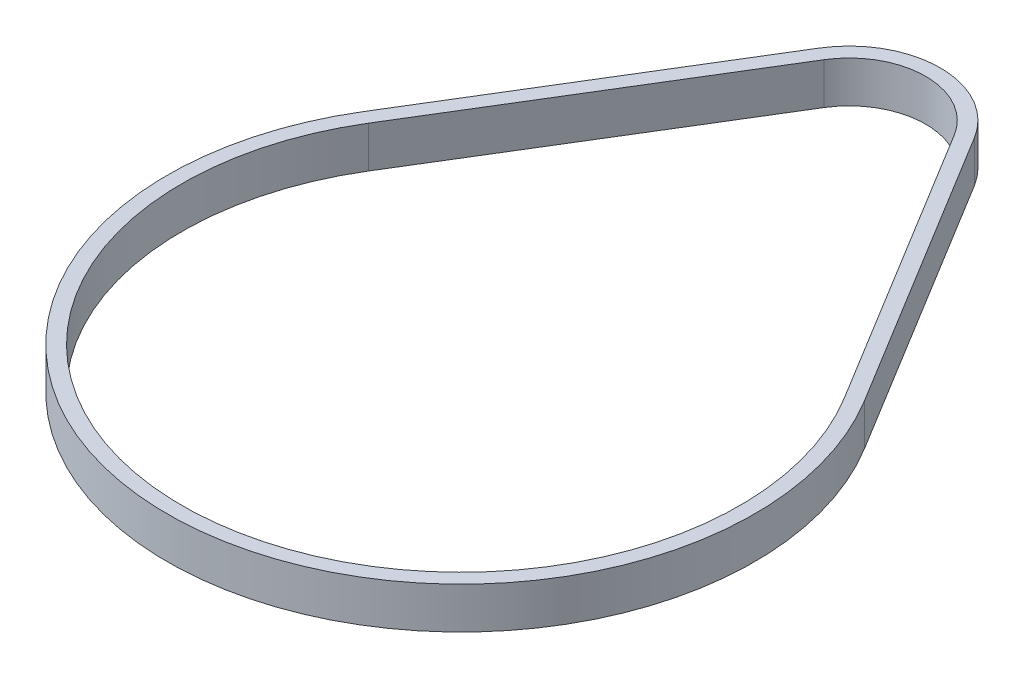
from build123d import *

# Parameters (mm, degrees)
BOSS_EXTRUDE1_DEPTH = 9


with BuildPart() as part:
    # Sketch1 → Boss-Extrude1 (new body)
    with BuildSketch(Plane(origin=(0, 0, 0), x_dir=(1, 0, 0), z_dir=(0, 1, 0))):
        with BuildLine():
            Line((-54.356466247, 33.218553059), (-16.861774617, 94.572186868))
            ThreePointArc((-16.861774617, 94.572186868), (0, 104.028748), (16.861774617, 94.572186868))
            Line((16.861774617, 94.572186868), (54.356466247, 33.218553059))
            ThreePointArc((54.356466247, 33.218553059), (0, -63.7032), (-54.356466247, 33.218553059))
        make_face()
        with BuildLine():
            Line((-51.647312228, 31.562923421), (-14.152620598, 92.91655723))
            ThreePointArc((-14.152620598, 92.91655723), (0, 100.853748), (14.152620598, 92.91655723))
            Line((14.152620598, 92.91655723), (51.647312228, 31.562923421))
            ThreePointArc((51.647312228, 31.562923421), (0, -60.5282), (-51.647312228, 31.562923421))
        make_face(mode=Mode.SUBTRACT)
    extrude(amount=BOSS_EXTRUDE1_DEPTH)


solid = part.part
